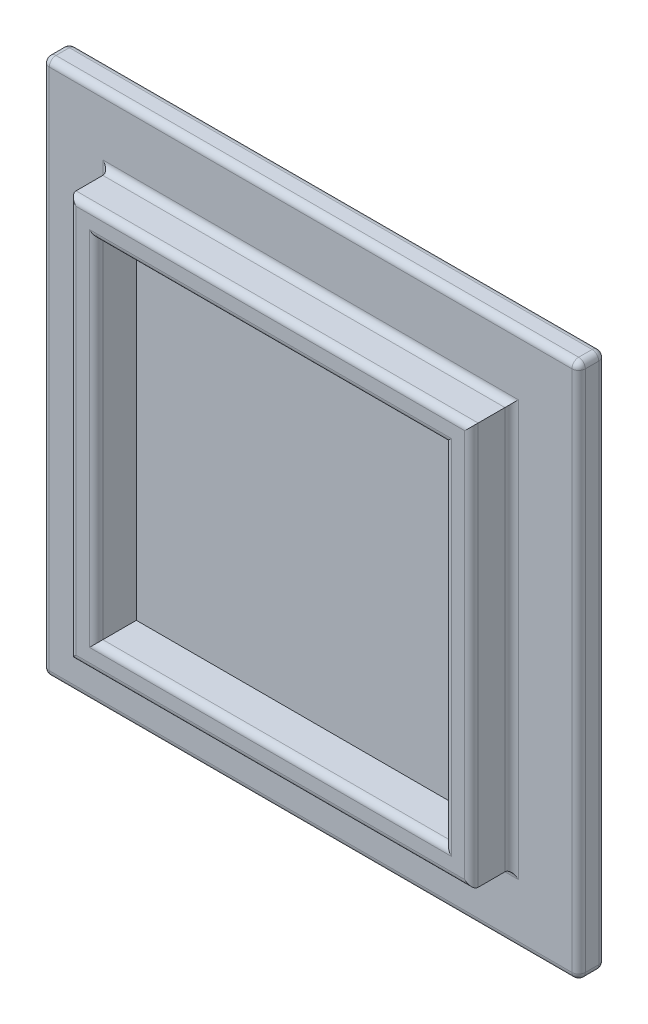
from build123d import *

# Parameters (mm, degrees)
SKETCH1_W           = 40
SKETCH1_H           = 40
BOSS_EXTRUDE1_DEPTH = 2
SKETCH2_W           = 30
SKETCH2_H           = 30
SKETCH2_W_2         = 26
SKETCH2_H_2         = 26
BOSS_EXTRUDE2_DEPTH = 3
FILLET1_R           = 0.5
FILLET2_R           = 0.5
FILLET3_R           = 0.5


with BuildPart() as part:
    # Sketch1 → Boss-Extrude1 (new body)
    with BuildSketch(Plane.XY):
        with Locations((-5.192307692, 0.701169798)):
            Rectangle(SKETCH1_W, SKETCH1_H)
    extrude(amount=BOSS_EXTRUDE1_DEPTH)

    # Sketch2 → Boss-Extrude2 (add)
    with BuildSketch(Plane.XY.offset(2)):
        with Locations((-5.192307692, 0.701169798)):
            Rectangle(SKETCH2_W, SKETCH2_H)
        with Locations((-5.192307692, 0.701169798)):
            Rectangle(SKETCH2_W_2, SKETCH2_H_2, mode=Mode.SUBTRACT)
    extrude(amount=BOSS_EXTRUDE2_DEPTH)

    # Fillet1
    fillet1_edges = [part.edges().sort_by_distance(p)[0] for p in [
        (-20.192307692, 0.701169798, 5),
        (-5.192307692, -14.298830202, 5),
        (9.807692308, 0.701169798, 5),
        (-5.192307692, 15.701169798, 5),
        (-18.192307692, 0.701169798, 5),
        (-5.192307692, -12.298830202, 5),
        (7.807692308, 0.701169798, 5),
        (-5.192307692, 13.701169798, 5),
    ]]
    fillet(fillet1_edges, radius=FILLET1_R)

    # Fillet2
    fillet2_edges = [part.edges().sort_by_distance(p)[0] for p in [
        (14.807692308, 0.701169798, 2),
        (-5.192307692, 20.701169798, 2),
        (-25.192307692, 0.701169798, 2),
        (-5.192307692, 20.701169798, 0),
        (14.807692308, 0.701169798, 0),
        (-5.192307692, -19.298830202, 0),
        (-25.192307692, 0.701169798, 0),
        (-25.192307692, 20.701169798, 1),
        (14.807692308, 20.701169798, 1),
        (14.807692308, -19.298830202, 1),
        (-25.192307692, -19.298830202, 1),
        (-5.192307692, -19.298830202, 2),
    ]]
    fillet(fillet2_edges, radius=FILLET2_R)

    # Fillet3
    fillet3_edges = [part.edges().sort_by_distance(p)[0] for p in [
        (-20.192307692, 0.701169798, 2),
        (-5.192307692, -14.298830202, 2),
        (9.807692308, 0.701169798, 2),
        (-5.192307692, 15.701169798, 2),
    ]]
    fillet(fillet3_edges, radius=FILLET3_R)


solid = part.part
